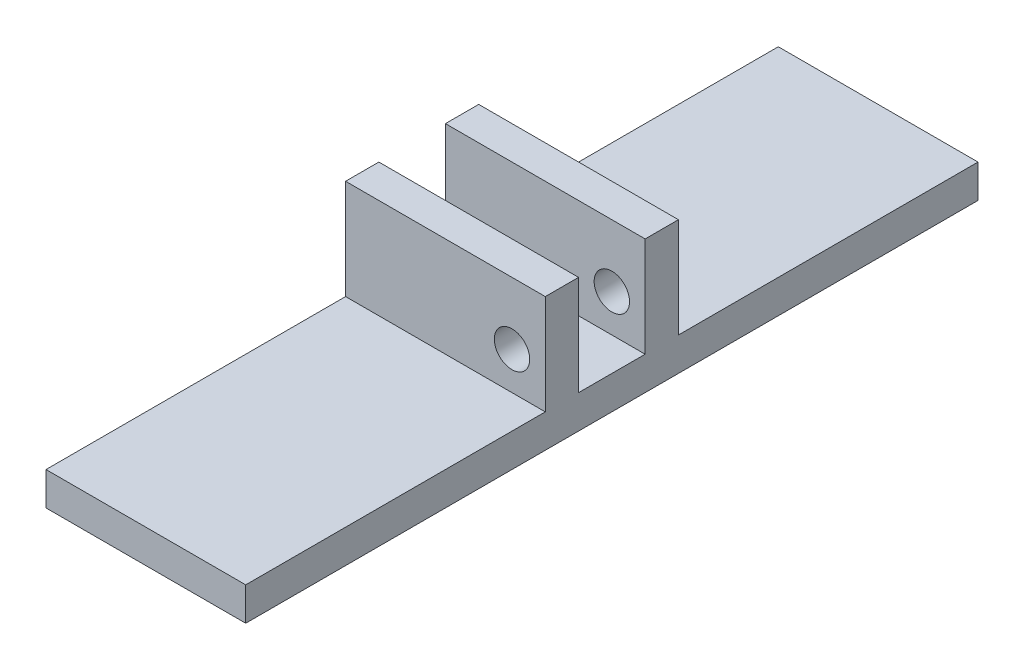
from build123d import *

# Parameters (mm, degrees)
BOSS_EXTRUDE1_DEPTH     = 38.1
F_1_4_CLEARANCE_HOLE3_D = 6.7564


with BuildPart() as part:
    # Sketch1 → Boss-Extrude1 (new body)
    with BuildSketch(Plane(origin=(0, 0, 0), x_dir=(0, 0, -1), z_dir=(1, 0, 0))):
        Polygon((-69.85, 0), (69.85, 0), (69.85, 6.35), (12.7, 6.35), (12.7, 25.4), (6.35, 25.4), (6.35, 6.35), (-6.35, 6.35), (-6.35, 25.4), (-12.7, 25.4), (-12.7, 6.35), (-69.85, 6.35), align=None)
    extrude(amount=BOSS_EXTRUDE1_DEPTH)

    # 1/4 Clearance Hole3 (through all)
    with Locations(Plane.XY.offset(12.7)):
        with Locations((31.75, 13.5255)):
            Hole(F_1_4_CLEARANCE_HOLE3_D / 2)


solid = part.part
